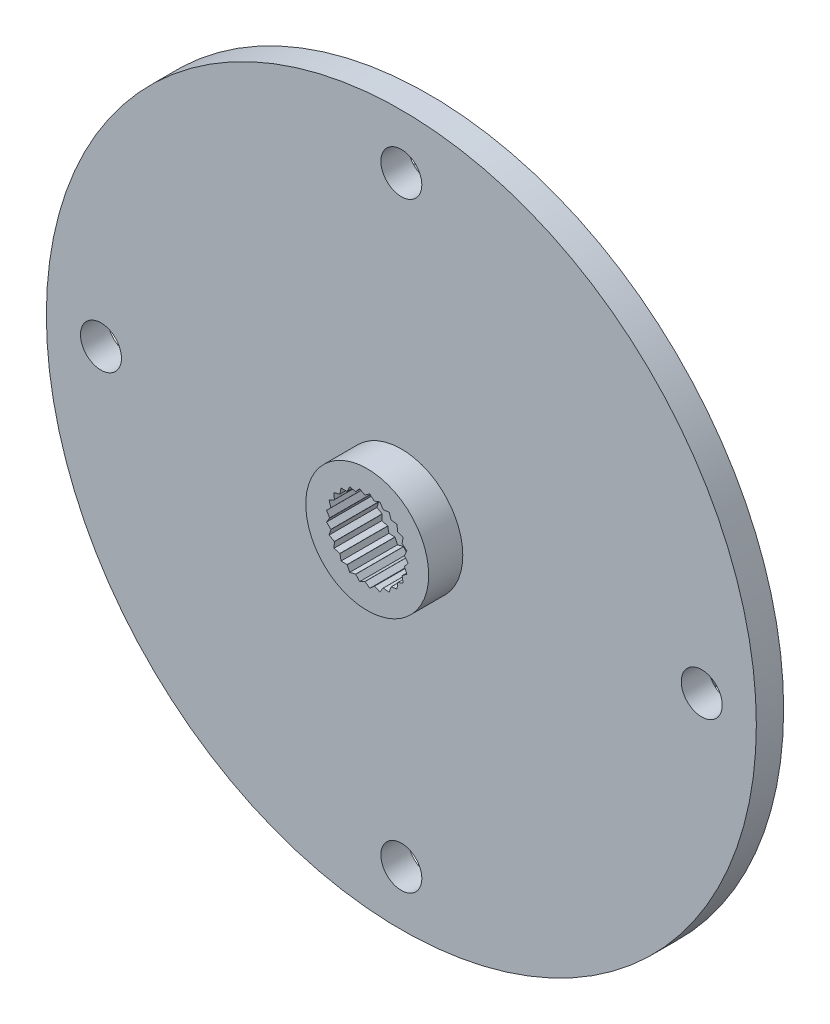
from build123d import *

# Parameters (mm, degrees)
SKETCH1_R           = 26
SKETCH1_R_2         = 1.5
SKETCH1_R_3         = 4.5
BOSS_EXTRUDE1_DEPTH = 2
SKETCH1_2_R         = 4.5
BOSS_EXTRUDE2_DEPTH = 4.5
SKETCH2_R           = 1.5
CUT_EXTRUDE1_DEPTH  = 4.5
SKETCH3_R           = 2.75
CUT_EXTRUDE2_DEPTH  = 3.5
CUT_EXTRUDE3_DEPTH  = 3.5
CIRPATTERN1_COUNT   = 25
BOSS_EXTRUDE3_START = 3
SKETCH5_R           = 18.5
SKETCH5_R_2         = 1.5
BOSS_EXTRUDE3_DEPTH = 3


with BuildPart() as part:
    # Sketch1 → Boss-Extrude1 (new body)
    with BuildSketch(Plane.XY):
        Circle(SKETCH1_R)
        with Locations((0, 22)):
            Circle(SKETCH1_R_2, mode=Mode.SUBTRACT)
        with Locations((22, 0)):
            Circle(SKETCH1_R_2, mode=Mode.SUBTRACT)
        with Locations((0, -22)):
            Circle(SKETCH1_R_2, mode=Mode.SUBTRACT)
        with Locations((-22, 0)):
            Circle(SKETCH1_R_2, mode=Mode.SUBTRACT)
        Circle(SKETCH1_R_3, mode=Mode.SUBTRACT)
    extrude(amount=BOSS_EXTRUDE1_DEPTH)

    # Sketch1_2 → Boss-Extrude2 (add)
    with BuildSketch(Plane.XY):
        Circle(SKETCH1_2_R)
    extrude(amount=BOSS_EXTRUDE2_DEPTH)

    # Sketch2 → Cut-Extrude1 (cut)
    with BuildSketch(Plane(origin=(0, 0, 0), x_dir=(-1, 0, 0), z_dir=(0, 0, -1))):
        Circle(SKETCH2_R)
    extrude(amount=-CUT_EXTRUDE1_DEPTH, mode=Mode.SUBTRACT)

    # Sketch3 → Cut-Extrude2 (cut)
    with BuildSketch(Plane.XY.offset(4.5)):
        Circle(SKETCH3_R)
    extrude(amount=-CUT_EXTRUDE2_DEPTH, mode=Mode.SUBTRACT)

    # Sketch4 → Cut-Extrude3 (cut)
    with BuildSketch(Plane.XY.offset(4.5)):
        with BuildLine():
            Line((-2.976344104, 0.375999701), (-2.75, 0))
            ThreePointArc((-2.75, 0), (-2.728912829, 0.339904061), (-2.665974712, 0.674595311))
            Line((-2.665974712, 0.674595311), (-2.976344104, 0.375999701))
        make_face()
    cut_extrude3 = extrude(amount=-CUT_EXTRUDE3_DEPTH, mode=Mode.SUBTRACT)

    # CirPattern1: Cut-Extrude3 ×25 about axis
    cirpattern1_axis = Axis((0, 0, 4.5), (0, 0, -1))
    for i in range(1, CIRPATTERN1_COUNT):
        add(cut_extrude3.rotate(cirpattern1_axis, i * 360 / CIRPATTERN1_COUNT), mode=Mode.SUBTRACT)

    # Sketch5 → Boss-Extrude3 (add)
    with BuildSketch(Plane(origin=(0, 0, 0), x_dir=(-1, 0, 0), z_dir=(0, 0, -1)).offset(BOSS_EXTRUDE3_START)):
        Circle(SKETCH5_R)
        Circle(SKETCH5_R_2, mode=Mode.SUBTRACT)
    extrude(amount=-BOSS_EXTRUDE3_DEPTH)


solid = part.part
